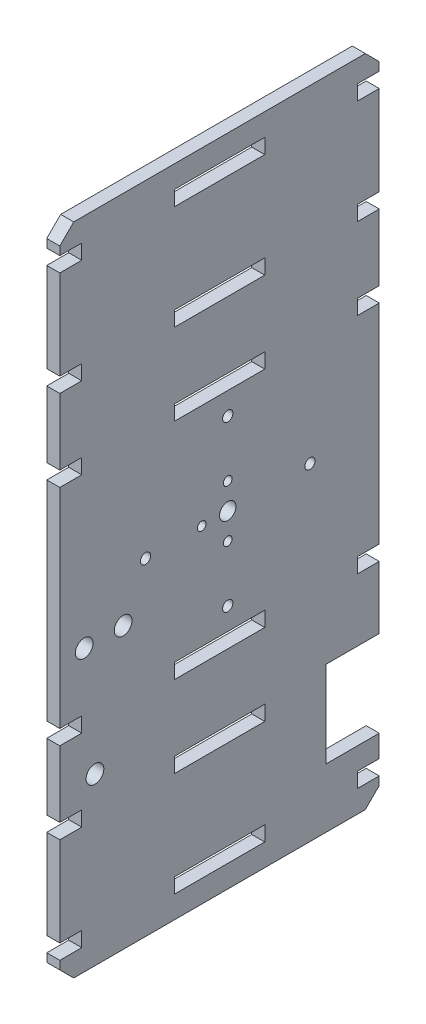
from build123d import *

# Parameters (mm, degrees)
SKETCH1_R           = 1.5875
SKETCH1_R_2         = 3
SKETCH1_R_3         = 3.2385
SKETCH1_R_4         = 1.8669
SKETCH1_W           = 33.02
SKETCH1_H           = 5.461
BOSS_EXTRUDE1_DEPTH = 4.7625
CHAMFER1_SIZE       = 5.08


with BuildPart() as part:
    # Sketch1 → Boss-Extrude1 (new body)
    with BuildSketch(Plane(origin=(0, 0, 0), x_dir=(0, 0, -1), z_dir=(1, 0, 0))):
        Polygon((-58.293, 119.489), (58.293, 119.489), (58.293, 111.361), (50.293, 111.361), (50.293, 105.9), (58.293, 105.9), (58.293, 73.261), (50.293, 73.261), (50.293, 67.8), (58.293, 67.8), (58.293, 43.561), (50.293, 43.561), (50.293, 38.1), (58.293, 38.1), (58.293, -38.1), (50.293, -38.1), (50.293, -43.561), (58.293, -43.561), (58.293, -66.374), (38.857, -66.374), (38.857, -97.87), (58.293, -97.87), (58.293, -105.9), (50.293, -105.9), (50.293, -111.361), (58.293, -111.361), (58.293, -119.489), (-58.293, -119.489), (-58.293, -111.361), (-50.293, -111.361), (-50.293, -105.9), (-58.293, -105.9), (-58.293, -73.261), (-50.293, -73.261), (-50.293, -67.8), (-58.293, -67.8), (-58.293, -43.561), (-50.293, -43.561), (-50.293, -38.1), (-58.293, -38.1), (-58.293, 38.1), (-50.293, 38.1), (-50.293, 43.561), (-58.293, 43.561), (-58.293, 67.8), (-50.293, 67.8), (-50.293, 73.261), (-58.293, 73.261), (-58.293, 105.9), (-50.293, 105.9), (-50.293, 111.361), (-58.293, 111.361), align=None)
        with Locations((3, 9.519071488)):
            Circle(SKETCH1_R, mode=Mode.SUBTRACT)
        with Locations((-6.519071488, 0)):
            Circle(SKETCH1_R, mode=Mode.SUBTRACT)
        with Locations((3, -9.519071488)):
            Circle(SKETCH1_R, mode=Mode.SUBTRACT)
        with Locations((3, 0)):
            Circle(SKETCH1_R_2, mode=Mode.SUBTRACT)
        with Locations((-35.174, -17.15)):
            Circle(SKETCH1_R_3, mode=Mode.SUBTRACT)
        with Locations((-49.398, -17.15)):
            Circle(SKETCH1_R_3, mode=Mode.SUBTRACT)
        with Locations((-45.464, -58.872973782)):
            Circle(SKETCH1_R_3, mode=Mode.SUBTRACT)
        with Locations((33, 0)):
            Circle(SKETCH1_R_4, mode=Mode.SUBTRACT)
        with Locations((3, 30)):
            Circle(SKETCH1_R_4, mode=Mode.SUBTRACT)
        with Locations((-27, 0)):
            Circle(SKETCH1_R_4, mode=Mode.SUBTRACT)
        with Locations((3, -30)):
            Circle(SKETCH1_R_4, mode=Mode.SUBTRACT)
        with Locations((0, 108.6305)):
            Rectangle(SKETCH1_W, SKETCH1_H, mode=Mode.SUBTRACT)
        with Locations((0, 70.5305)):
            Rectangle(SKETCH1_W, SKETCH1_H, mode=Mode.SUBTRACT)
        with Locations((0, 40.8305)):
            Rectangle(SKETCH1_W, SKETCH1_H, mode=Mode.SUBTRACT)
        with Locations((0, -40.8305)):
            Rectangle(SKETCH1_W, SKETCH1_H, mode=Mode.SUBTRACT)
        with Locations((0, -70.5305)):
            Rectangle(SKETCH1_W, SKETCH1_H, mode=Mode.SUBTRACT)
        with Locations((0, -108.6305)):
            Rectangle(SKETCH1_W, SKETCH1_H, mode=Mode.SUBTRACT)
    extrude(amount=-BOSS_EXTRUDE1_DEPTH)

    # Chamfer1
    chamfer1_edges = [part.edges().sort_by_distance(p)[0] for p in [
        (-2.38125, 119.489, 58.293),
        (-2.38125, 119.489, -58.293),
        (-2.38125, -119.489, 58.293),
        (-2.38125, -119.489, -58.293),
    ]]
    chamfer(chamfer1_edges, length=CHAMFER1_SIZE)


solid = part.part
